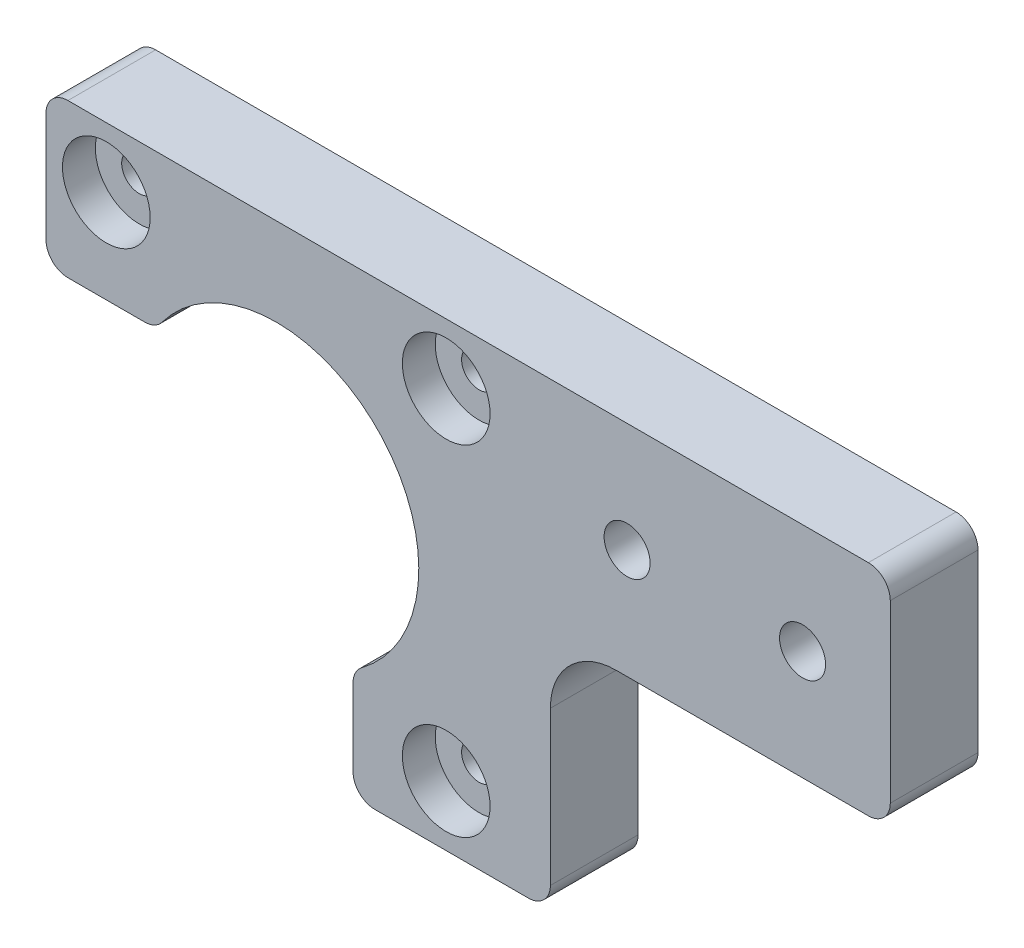
from build123d import *

# Parameters (mm, degrees)
ESQUISSE1_W             = 77
ESQUISSE1_H             = 42
BOSS_EXTRU_1_DEPTH      = 8
ESQUISSE3_R             = 4
ENL_V_MAT_EXTRU_1_DEPTH = 3
ESQUISSE4_R             = 13
ENL_V_MAT_EXTRU_2_DEPTH = 9
ESQUISSE5_W             = 28
ESQUISSE5_H             = 28
ENL_V_MAT_EXTRU_3_DEPTH = 9
ESQUISSE10_R            = 1.6
ENL_V_MAT_EXTRU_4_DEPTH = 6
ESQUISSE11_W            = 31
ESQUISSE11_H            = 22
ENL_V_MAT_EXTRU_5_DEPTH = 9
ESQUISSE12_R            = 2.1
ENL_V_MAT_EXTRU_6_DEPTH = 9
CONG_1_R                = 6
CONG_2_R                = 2


with BuildPart() as part:
    # Esquisse1 → Boss.-Extru.1 (new body)
    with BuildSketch(Plane.XY):
        with Locations((38.5, 21)):
            Rectangle(ESQUISSE1_W, ESQUISSE1_H)
    extrude(amount=BOSS_EXTRU_1_DEPTH)

    # Esquisse3 → Enlèv. mat.-Extru.1 (cut)
    with BuildSketch(Plane.XY.offset(8)):
        with Locations((5.5, 36.5)):
            Circle(ESQUISSE3_R)
        with Locations((36.5, 36.5)):
            Circle(ESQUISSE3_R)
        with Locations((36.5, 5.5)):
            Circle(ESQUISSE3_R)
    extrude(amount=-ENL_V_MAT_EXTRU_1_DEPTH, mode=Mode.SUBTRACT)

    # Esquisse4 → Enlèv. mat.-Extru.2 (cut, through all)
    with BuildSketch(Plane.XY.offset(8)):
        with Locations((21, 21)):
            Circle(ESQUISSE4_R)
    extrude(amount=-ENL_V_MAT_EXTRU_2_DEPTH, mode=Mode.SUBTRACT)

    # Esquisse5 → Enlèv. mat.-Extru.3 (cut, through all)
    with BuildSketch(Plane.XY.offset(8)):
        with Locations((14, 14)):
            Rectangle(ESQUISSE5_W, ESQUISSE5_H)
    extrude(amount=-ENL_V_MAT_EXTRU_3_DEPTH, mode=Mode.SUBTRACT)

    # Esquisse10 → Enlèv. mat.-Extru.4 (cut, through all)
    with BuildSketch(Plane.XY.offset(5)):
        with Locations((5.5, 36.5)):
            Circle(ESQUISSE10_R)
        with Locations((36.5, 36.5)):
            Circle(ESQUISSE10_R)
        with Locations((36.5, 5.5)):
            Circle(ESQUISSE10_R)
    extrude(amount=-ENL_V_MAT_EXTRU_4_DEPTH, mode=Mode.SUBTRACT)

    # Esquisse11 → Enlèv. mat.-Extru.5 (cut, through all)
    with BuildSketch(Plane.XY.offset(8)):
        with Locations((61.5, 11)):
            Rectangle(ESQUISSE11_W, ESQUISSE11_H)
    extrude(amount=-ENL_V_MAT_EXTRU_5_DEPTH, mode=Mode.SUBTRACT)

    # Esquisse12 → Enlèv. mat.-Extru.6 (cut, through all)
    with BuildSketch(Plane.XY.offset(8)):
        with Locations((53, 32)):
            Circle(ESQUISSE12_R)
        with Locations((69, 32)):
            Circle(ESQUISSE12_R)
    extrude(amount=-ENL_V_MAT_EXTRU_6_DEPTH, mode=Mode.SUBTRACT)

    # Congé1
    cong_1_edges = [part.edges().sort_by_distance(p)[0] for p in [
        (46, 22, 4),
    ]]
    fillet(cong_1_edges, radius=CONG_1_R)

    # Congé2
    cong_2_edges = [part.edges().sort_by_distance(p)[0] for p in [
        (28, 10.04554885, 4),
        (10.04554885, 28, 4),
        (0, 28, 4),
        (28, 0, 4),
        (77, 22, 4),
        (46, 0, 4),
        (0, 42, 4),
        (77, 42, 4),
    ]]
    fillet(cong_2_edges, radius=CONG_2_R)


solid = part.part
